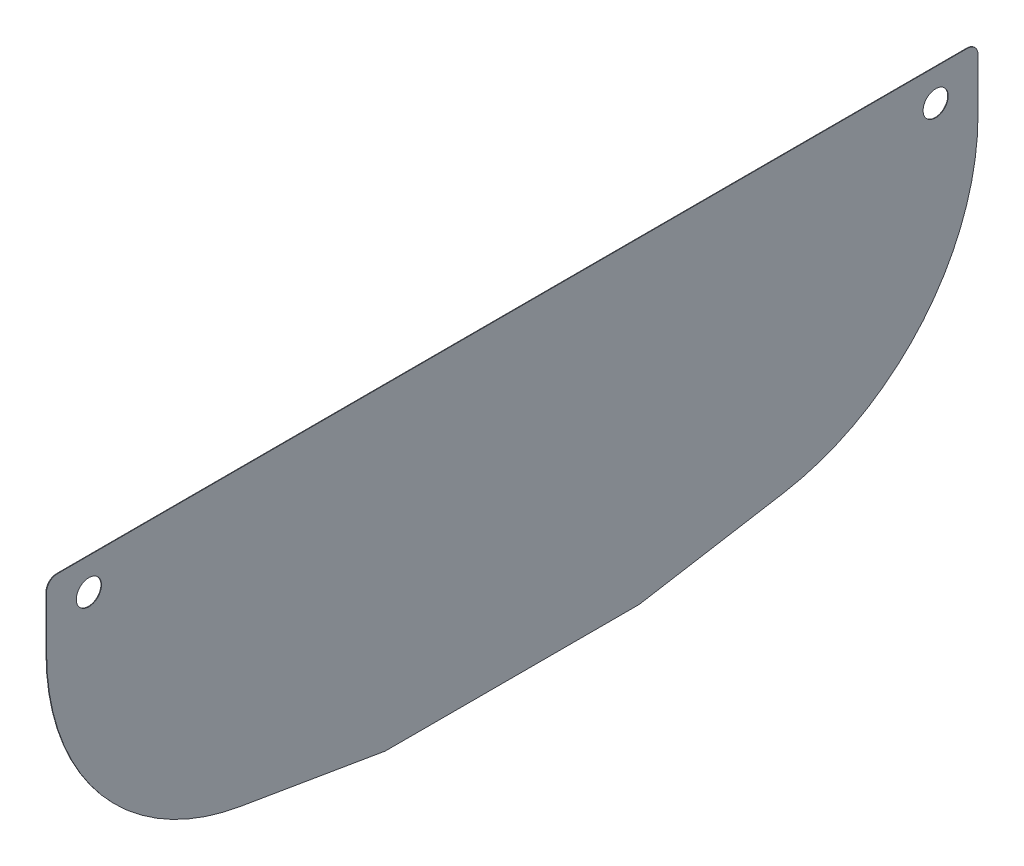
from build123d import *

# Parameters (mm, degrees)
SKETCH1_R           = 15.08125
BOSS_EXTRUDE1_DEPTH = 0.635
FILLET1_R           = 12.7


with BuildPart() as part:
    # Sketch1 → Boss-Extrude1 (new body)
    with BuildSketch(Plane(origin=(0, 0, 0), x_dir=(0, 0, -1), z_dir=(1, 0, 0))):
        with BuildLine():
            Line((-558.8, 609.6), (-558.8, 685.8))
            Line((-558.8, 685.8), (558.8, 685.8))
            Line((558.8, 685.8), (558.8, 609.6))
            ThreePointArc((558.8, 609.6), (492.779998657, 429.230002015), (325.91999876, 334.100000517))
            Line((325.91999876, 334.100000517), (152.4, 304.8))
            Line((152.4, 304.8), (-152.4, 304.8))
            Line((-152.4, 304.8), (-325.91999876, 334.100000517))
            ThreePointArc((-325.91999876, 334.100000517), (-492.779998657, 429.230002015), (-558.8, 609.6))
        make_face()
        with Locations((-508, 647.7)):
            Circle(SKETCH1_R, mode=Mode.SUBTRACT)
        with Locations((508, 647.7)):
            Circle(SKETCH1_R, mode=Mode.SUBTRACT)
    extrude(amount=BOSS_EXTRUDE1_DEPTH)

    # Fillet1
    fillet1_edges = [part.edges().sort_by_distance(p)[0] for p in [
        (0.3175, 304.8, -152.4),
        (0.3175, 304.8, 152.4),
        (0.3175, 685.8, 558.8),
        (0.3175, 685.8, -558.8),
    ]]
    fillet(fillet1_edges, radius=FILLET1_R)


solid = part.part
